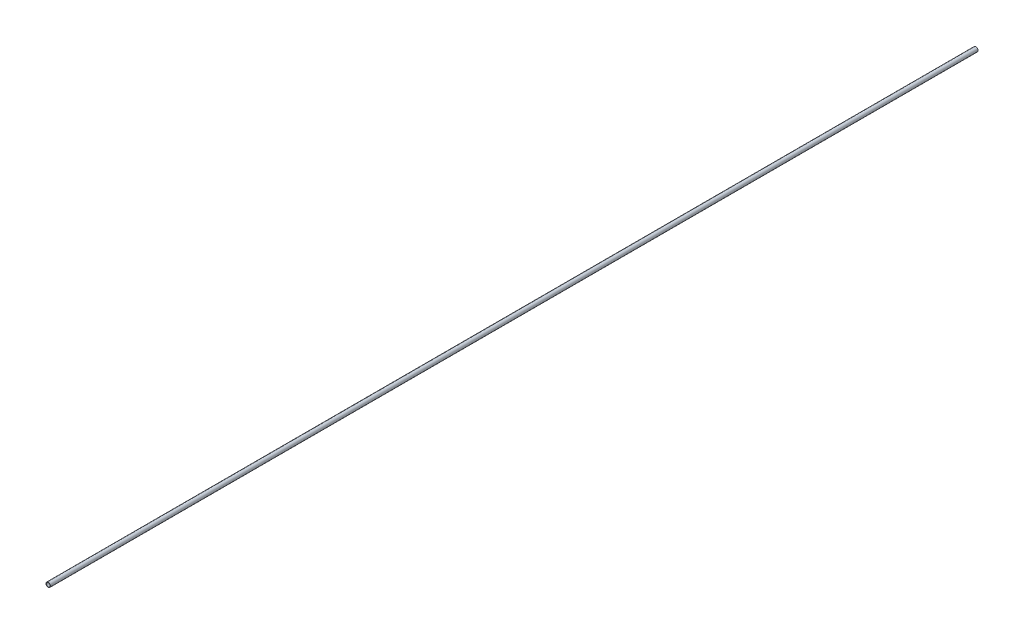
from build123d import *

# Parameters (mm, degrees)
SKETCH1_R           = 2.5
SKETCH1_R_2         = 2
EXTRUDE_THIN1_DEPTH = 523


with BuildPart() as part:
    # Sketch1 → Extrude-Thin1 (new body, symmetric)
    with BuildSketch(Plane.XY):
        Circle(SKETCH1_R)
        Circle(SKETCH1_R_2, mode=Mode.SUBTRACT)
    extrude(amount=EXTRUDE_THIN1_DEPTH, both=True)


solid = part.part
